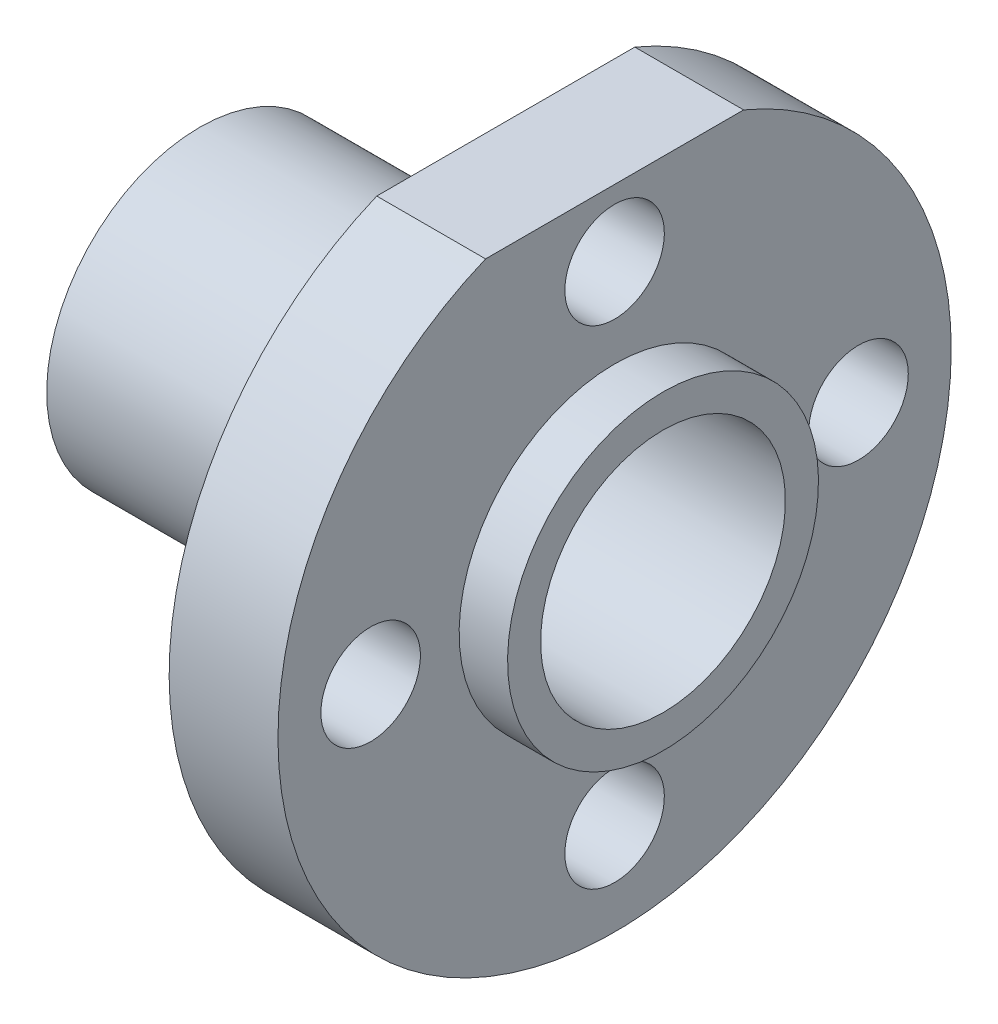
from build123d import *

# Parameters (mm, degrees)
SKETCH2_R          = 1.6256
CUT_EXTRUDE1_DEPTH = 3.556
CIRPATTERN1_COUNT  = 4
CUT_EXTRUDE2_DEPTH = 3.556


with BuildPart() as part:
    # Sketch1 → Revolve1 (revolve)
    with BuildSketch(Plane.XY):
        Polygon((-15.1384, 4.99999), (-5.1384, 4.99999), (-5.1384, 11), (-1.5824, 11), (-1.5824, 5.08), (0, 5.08), (0, 4), (-15.1384, 4), align=None)
    revolve(axis=Axis((0, 0, 0), (-1, 0, 0)))

    # Sketch2 → Cut-Extrude1 (cut)
    with BuildSketch(Plane(origin=(-1.5824, 0, 0), x_dir=(0, 0, -1), z_dir=(1, 0, 0))):
        with Locations((0, 7.97105)):
            Circle(SKETCH2_R)
    cut_extrude1 = extrude(amount=-CUT_EXTRUDE1_DEPTH, mode=Mode.SUBTRACT)

    # CirPattern1: Cut-Extrude1 ×4 about axis
    cirpattern1_axis = Axis((0, 0, 0), (1, 0, 0))
    for i in range(1, CIRPATTERN1_COUNT):
        add(cut_extrude1.rotate(cirpattern1_axis, i * 360 / CIRPATTERN1_COUNT), mode=Mode.SUBTRACT)

    # Sketch3 → Cut-Extrude2 (cut)
    with BuildSketch(Plane(origin=(-1.5824, 0, 0), x_dir=(0, 0, -1), z_dir=(1, 0, 0))):
        with BuildLine():
            Line((-4.215969639, 10.16), (4.215969639, 10.16))
            ThreePointArc((4.215969639, 10.16), (0, 11), (-4.215969639, 10.16))
        make_face()
    extrude(amount=-CUT_EXTRUDE2_DEPTH, mode=Mode.SUBTRACT)


solid = part.part
